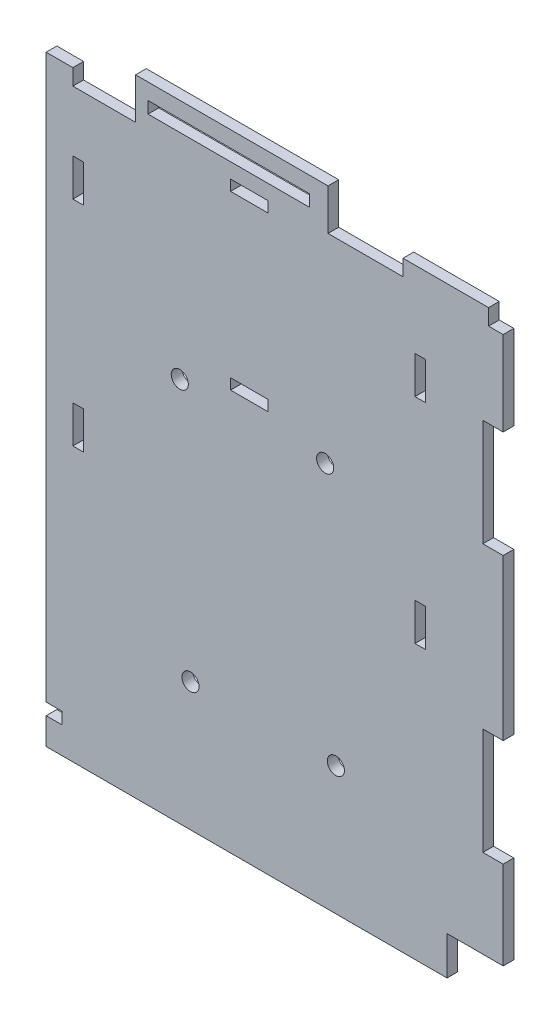
from build123d import *

# Parameters (mm, degrees)
AUFSATZ_LINEAR_AUSTRAGEN1_DEPTH = 2
SKIZZE2_R                       = 1.6
SKIZZE2_W                       = 2
SKIZZE2_H                       = 7
SKIZZE2_W_2                     = 7
SKIZZE2_H_2                     = 2
SCHNITT_LINEAR_AUSTRAGEN1_DEPTH = 2
SKIZZE3_W                       = 30.2
SKIZZE3_H                       = 2.2
SCHNITT_LINEAR_AUSTRAGEN2_DEPTH = 2


with BuildPart() as part:
    # Skizze1 → Aufsatz-Linear austragen1 (new body)
    with BuildSketch(Plane.XY):
        Polygon((39.278745883, -130.531139266), (-35.721254117, -130.531139266), (-35.721254117, -125.531139266), (-32.721254117, -125.531139266), (-32.721254117, -123.331139266), (-35.721254117, -123.331139266), (-35.721254117, -18.031139266), (-30.721254117, -18.031139266), (-30.721254117, -21.031139266), (-28.689548947, -21.031139266), (-23.428125466, -21.031139266), (-18.990357652, -21.031139266), (-18.990357652, -13.331139266), (17.009642348, -13.331139266), (17.009642348, -21.031139266), (22.500868798, -21.031139266), (28.500868798, -21.031139266), (31.045701771, -21.031139266), (31.045701771, -18.031139266), (47.045701771, -18.031139266), (47.045701771, -21.031139266), (49.778745883, -21.031139266), (49.778745883, -36.831139266), (45.978745883, -36.831139266), (45.978745883, -56.831139266), (49.778745883, -56.831139266), (49.778745883, -86.831139266), (45.978745883, -86.831139266), (45.978745883, -106.831139266), (49.778745883, -106.831139266), (49.778745883, -123.331139266), (39.278745883, -123.331139266), align=None)
    extrude(amount=AUFSATZ_LINEAR_AUSTRAGEN1_DEPTH)

    # Skizze2 → Schnitt-Linear austragen1 (cut)
    with BuildSketch(Plane.XY.offset(2)):
        with Locations((-10.721254117, -58.531139266)):
            Circle(SKIZZE2_R)
        with Locations((16.478745883, -58.531139266)):
            Circle(SKIZZE2_R)
        with Locations((-8.721254117, -106.531139266)):
            Circle(SKIZZE2_R)
        with Locations((18.478745883, -106.531139266)):
            Circle(SKIZZE2_R)
        with Locations((-29.721254117, -35.831139266)):
            Rectangle(SKIZZE2_W, SKIZZE2_H)
        with Locations((34.278745883, -35.831139266)):
            Rectangle(SKIZZE2_W, SKIZZE2_H)
        with Locations((-29.721254117, -75.831139266)):
            Rectangle(SKIZZE2_W, SKIZZE2_H)
        with Locations((34.278745883, -75.831139266)):
            Rectangle(SKIZZE2_W, SKIZZE2_H)
        with Locations((2.278745883, -54.531139266)):
            Rectangle(SKIZZE2_W_2, SKIZZE2_H_2)
        with Locations((2.278745883, -22.331139266)):
            Rectangle(SKIZZE2_W_2, SKIZZE2_H_2)
    extrude(amount=-SCHNITT_LINEAR_AUSTRAGEN1_DEPTH, mode=Mode.SUBTRACT)

    # Skizze3 → Schnitt-Linear austragen2 (cut)
    with BuildSketch(Plane.XY.offset(2)):
        with Locations((-1.561818921, -17.431139266)):
            Rectangle(SKIZZE3_W, SKIZZE3_H)
    extrude(amount=-SCHNITT_LINEAR_AUSTRAGEN2_DEPTH, mode=Mode.SUBTRACT)


solid = part.part
